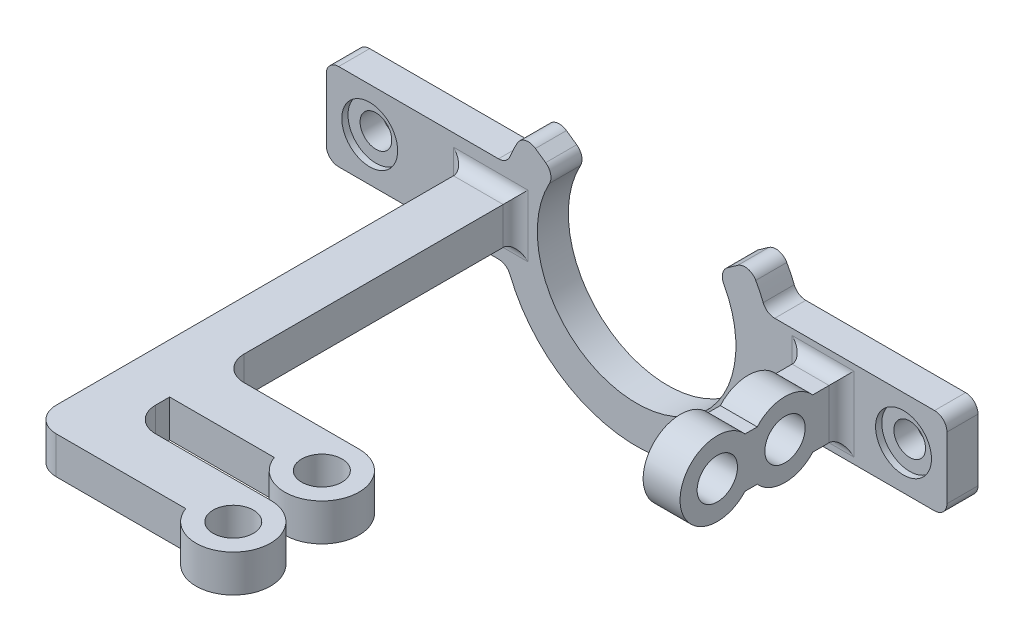
from build123d import *

# Parameters (mm, degrees)
SKETCH1_R                = 2.55
BOSS_EXTRUDE1_DEPTH      = 5
SKETCH4_R                = 4.5
CUT_EXTRUDE2_DEPTH       = 1
SKETCH6_W                = 5.947651005
SKETCH6_H                = 20
BOSS_EXTRUDE2_DEPTH      = 4
BOSS_EXTRUDE2_DEPTH_BACK = 4
SKETCH11_R               = 4.5
CUT_EXTRUDE3_DEPTH       = 0.5
SKETCH16_R               = 3.25
BOSS_EXTRUDE3_DEPTH      = 3
BOSS_EXTRUDE3_DEPTH_BACK = 3
FILLET3_R                = 2
BOSS_EXTRUDE4_DEPTH      = 5.947651
CUT_EXTRUDE5_REACH       = 85
SKETCH18_R               = 3.25


with BuildPart() as part:
    # Sketch1 → Boss-Extrude1 (new body)
    with BuildSketch(Plane.XY):
        with BuildLine():
            Line((100, 25), (100, 20))
            ThreePointArc((100, 20), (99.414213562, 18.585786438), (98, 18))
            Line((98, 18), (72.248595461, 18))
            ThreePointArc((72.248595461, 18), (71.130561473, 17.658312395), (70.39454584, 16.75))
            ThreePointArc((70.39454584, 16.75), (50, 3), (29.60545416, 16.75))
            ThreePointArc((29.60545416, 16.75), (28.869438527, 17.658312395), (27.751404539, 18))
            Line((27.751404539, 18), (2, 18))
            ThreePointArc((2, 18), (0.585786438, 18.585786438), (0, 20))
            Line((0, 20), (0, 25))
            Line((0, 25), (0, 30))
            ThreePointArc((0, 30), (0.585786438, 31.414213562), (2, 32))
            Line((2, 32), (21.056240945, 32))
            Line((21.056240945, 32), (27.751404539, 32))
            ThreePointArc((27.751404539, 32), (28.869438527, 32.341687605), (29.60545416, 33.25))
            ThreePointArc((29.60545416, 33.25), (30.166752838, 34.520625347), (30.807119991, 35.753295167))
            ThreePointArc((30.807119991, 35.753295167), (32.106461975, 36.725482012), (33.699080137, 36.414026968))
            Line((33.699080137, 36.414026968), (35.34656276, 35.260447216))
            ThreePointArc((35.34656276, 35.260447216), (36.146649881, 34.078494315), (35.955031011, 32.664127224))
            ThreePointArc((35.955031011, 32.664127224), (50, 9), (64.044968989, 32.664127224))
            ThreePointArc((64.044968989, 32.664127224), (63.853350119, 34.078494315), (64.65343724, 35.260447216))
            Line((64.65343724, 35.260447216), (66.300919863, 36.414026968))
            ThreePointArc((66.300919863, 36.414026968), (67.893538025, 36.725482012), (69.192880009, 35.753295167))
            ThreePointArc((69.192880009, 35.753295167), (69.833247162, 34.520625347), (70.39454584, 33.25))
            ThreePointArc((70.39454584, 33.25), (71.130561473, 32.341687605), (72.248595461, 32))
            Line((72.248595461, 32), (78.943759055, 32))
            Line((78.943759055, 32), (98, 32))
            ThreePointArc((98, 32), (99.414213562, 31.414213562), (100, 30))
            Line((100, 30), (100, 25))
        make_face()
        with Locations((93, 25)):
            Circle(SKETCH1_R, mode=Mode.SUBTRACT)
        with Locations((7, 25)):
            Circle(SKETCH1_R, mode=Mode.SUBTRACT)
    extrude(amount=BOSS_EXTRUDE1_DEPTH)

    # Sketch4 → Cut-Extrude2 (cut)
    with BuildSketch(Plane.XY.offset(5)):
        with Locations((93, 25)):
            Circle(SKETCH4_R)
        with Locations((7, 25)):
            Circle(SKETCH4_R)
    extrude(amount=-CUT_EXTRUDE2_DEPTH, mode=Mode.SUBTRACT)

    # Sketch6 → Boss-Extrude2 (add, two sides)
    with BuildSketch(Plane(origin=(0, 25, 0), x_dir=(-1, 0, 0), z_dir=(0, -1, 0))) as boss_extrude2_sk:
        with Locations((-80.026174497, -15)):
            Rectangle(SKETCH6_W, SKETCH6_H)
    extrude(amount=BOSS_EXTRUDE2_DEPTH)
    extrude(boss_extrude2_sk.sketch, amount=-BOSS_EXTRUDE2_DEPTH_BACK)

    # Sketch11 → Cut-Extrude3 (cut)
    with BuildSketch(Plane(origin=(0, 0, 0), x_dir=(-1, 0, 0), z_dir=(0, 0, -1))):
        with Locations((-93, 25)):
            Circle(SKETCH11_R)
        with Locations((-7, 25)):
            Circle(SKETCH11_R)
    extrude(amount=-CUT_EXTRUDE3_DEPTH, mode=Mode.SUBTRACT)

    # Sketch16 → Boss-Extrude3 (add, two sides)
    with BuildSketch(Plane(origin=(0, 25, 0), x_dir=(-1, 0, 0), z_dir=(0, -1, 0))) as boss_extrude3_sk:
        with BuildLine():
            Line((-30.494270905, -5), (-22.494270905, -5))
            Line((-22.494270905, -5), (-22.494270905, -71))
            ThreePointArc((-22.494270905, -71), (-23.665843781, -73.828427125), (-26.494270905, -75))
            Line((-26.494270905, -75), (-30.494270905, -75))
            Line((-30.494270905, -75), (-47.361403242, -75))
            ThreePointArc((-47.361403242, -75), (-57.917236977, -76.464101615), (-53.018257491, -67))
            Line((-53.018257491, -67), (-34.494270905, -67))
            ThreePointArc((-34.494270905, -67), (-31.665843781, -65.828427125), (-30.494270905, -63))
            Line((-30.494270905, -63), (-30.494270905, -60.732138804))
            Line((-30.494270905, -60.732138804), (-47.361403242, -60.732138804))
            ThreePointArc((-47.361403242, -60.732138804), (-57.917236977, -62.196240419), (-53.018257491, -52.732138804))
            Line((-53.018257491, -52.732138804), (-34.494270905, -52.732138804))
            ThreePointArc((-34.494270905, -52.732138804), (-31.665843781, -51.560565928), (-30.494270905, -48.732138804))
            Line((-30.494270905, -48.732138804), (-30.494270905, -5))
        make_face()
        with Locations((-53.018257491, -73)):
            Circle(SKETCH16_R, mode=Mode.SUBTRACT)
        with Locations((-53.018257491, -58.732138804)):
            Circle(SKETCH16_R, mode=Mode.SUBTRACT)
    extrude(amount=BOSS_EXTRUDE3_DEPTH)
    extrude(boss_extrude3_sk.sketch, amount=-BOSS_EXTRUDE3_DEPTH_BACK)

    # Fillet3
    fillet3_edges = [part.edges().sort_by_distance(p)[0] for p in [
        (83, 25, 5),
        (80.026174498, 29, 5),
        (77.052348995, 25, 5),
        (80.026174498, 21, 5),
        (30.494270905, 25, 5),
        (26.494270905, 28, 5),
        (22.494270905, 25, 5),
        (26.494270905, 22, 5),
    ]]
    fillet(fillet3_edges, radius=FILLET3_R)

    # Sketch17 → Boss-Extrude4 (add)
    with BuildSketch(Plane(origin=(83, 0, 0), x_dir=(0, 0, -1), z_dir=(1, 0, 0))):
        with BuildLine():
            ThreePointArc((-19.547210182, 27.503414308), (-31, 25), (-19.547210182, 22.496585692))
            ThreePointArc((-19.547210182, 22.496585692), (-8.094420363, 25), (-19.547210182, 27.503414308))
        make_face()
    extrude(amount=-BOSS_EXTRUDE4_DEPTH)

    # Sketch18 → Cut-Extrude5 (cut, up to next)
    with BuildSketch(Plane(origin=(83, 0, 0), x_dir=(0, 0, -1), z_dir=(1, 0, 0)), mode=Mode.PRIVATE) as cut_extrude5_sk1:
        with Locations((-25, 25)):
            Circle(SKETCH18_R)
    cut_extrude5_tool1 = extrude(cut_extrude5_sk1.sketch, amount=-CUT_EXTRUDE5_REACH, mode=Mode.PRIVATE) & part.part
    add(cut_extrude5_tool1.solids().sort_by_distance((83, 25, 25))[0], mode=Mode.SUBTRACT)
    # Sketch18 → Cut-Extrude5 (cut, up to next)
    with BuildSketch(Plane(origin=(83, 0, 0), x_dir=(0, 0, -1), z_dir=(1, 0, 0)), mode=Mode.PRIVATE) as cut_extrude5_sk2:
        with Locations((-14.094420363, 25)):
            Circle(SKETCH18_R)
    cut_extrude5_tool2 = extrude(cut_extrude5_sk2.sketch, amount=-CUT_EXTRUDE5_REACH, mode=Mode.PRIVATE) & part.part
    add(cut_extrude5_tool2.solids().sort_by_distance((83, 25, 14.09442))[0], mode=Mode.SUBTRACT)


solid = part.part
